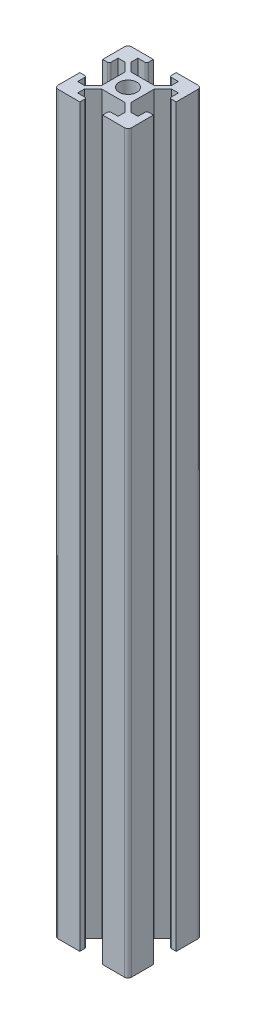
from build123d import *

# Parameters (mm, degrees)
SKETCH1_R           = 2.4
BOSS_EXTRUDE1_DEPTH = 200


with BuildPart() as part:
    # Sketch1 → Boss-Extrude1 (new body)
    with BuildSketch(Plane(origin=(0, 0, 0), x_dir=(1, 0, 0), z_dir=(0, 1, 0))):
        with BuildLine():
            ThreePointArc((-10, -9), (-9.707106781, -9.707106781), (-9, -10))
            Line((-9, -10), (-3.1, -10))
            Line((-3.1, -10), (-3.1, -8.7))
            ThreePointArc((-3.1, -8.7), (-3.246446609, -8.346446609), (-3.6, -8.2))
            Line((-3.6, -8.2), (-5.5, -8.2))
            Line((-5.5, -8.2), (-5.5, -6.376528763))
            Line((-5.5, -6.376528763), (-3.123471237, -4))
            Line((-3.123471237, -4), (0, -4))
            Line((0, -4), (3.123471237, -4))
            Line((3.123471237, -4), (5.5, -6.376528763))
            Line((5.5, -6.376528763), (5.5, -8.2))
            Line((5.5, -8.2), (3.6, -8.2))
            ThreePointArc((3.6, -8.2), (3.246446609, -8.346446609), (3.1, -8.7))
            Line((3.1, -8.7), (3.1, -10))
            Line((3.1, -10), (9, -10))
            ThreePointArc((9, -10), (9.707106781, -9.707106781), (10, -9))
            Line((10, -9), (10, -3.1))
            Line((10, -3.1), (8.7, -3.1))
            ThreePointArc((8.7, -3.1), (8.346446609, -3.246446609), (8.2, -3.6))
            Line((8.2, -3.6), (8.2, -5.5))
            Line((8.2, -5.5), (6.376528763, -5.5))
            Line((6.376528763, -5.5), (4, -3.123471237))
            Line((4, -3.123471237), (4, 0))
            Line((4, 0), (4, 3.123471237))
            Line((4, 3.123471237), (6.376528763, 5.5))
            Line((6.376528763, 5.5), (8.2, 5.5))
            Line((8.2, 5.5), (8.2, 3.6))
            ThreePointArc((8.2, 3.6), (8.346446609, 3.246446609), (8.7, 3.1))
            Line((8.7, 3.1), (10, 3.1))
            Line((10, 3.1), (10, 9))
            ThreePointArc((10, 9), (9.707106781, 9.707106781), (9, 10))
            Line((9, 10), (3.1, 10))
            Line((3.1, 10), (3.1, 8.7))
            ThreePointArc((3.1, 8.7), (3.246446609, 8.346446609), (3.6, 8.2))
            Line((3.6, 8.2), (5.5, 8.2))
            Line((5.5, 8.2), (5.5, 6.376528763))
            Line((5.5, 6.376528763), (3.123471237, 4))
            Line((3.123471237, 4), (0, 4))
            Line((0, 4), (-3.123471237, 4))
            Line((-3.123471237, 4), (-5.5, 6.376528763))
            Line((-5.5, 6.376528763), (-5.5, 8.2))
            Line((-5.5, 8.2), (-3.6, 8.2))
            ThreePointArc((-3.6, 8.2), (-3.246446609, 8.346446609), (-3.1, 8.7))
            Line((-3.1, 8.7), (-3.1, 10))
            Line((-3.1, 10), (-9, 10))
            ThreePointArc((-9, 10), (-9.707106781, 9.707106781), (-10, 9))
            Line((-10, 9), (-10, 3.1))
            Line((-10, 3.1), (-8.7, 3.1))
            ThreePointArc((-8.7, 3.1), (-8.346446609, 3.246446609), (-8.2, 3.6))
            Line((-8.2, 3.6), (-8.2, 5.5))
            Line((-8.2, 5.5), (-6.376528763, 5.5))
            Line((-6.376528763, 5.5), (-4, 3.123471237))
            Line((-4, 3.123471237), (-4, 0))
            Line((-4, 0), (-4, -3.123471237))
            Line((-4, -3.123471237), (-6.376528763, -5.5))
            Line((-6.376528763, -5.5), (-8.2, -5.5))
            Line((-8.2, -5.5), (-8.2, -3.6))
            ThreePointArc((-8.2, -3.6), (-8.346446609, -3.246446609), (-8.7, -3.1))
            Line((-8.7, -3.1), (-10, -3.1))
            Line((-10, -3.1), (-10, -9))
        make_face()
        Circle(SKETCH1_R, mode=Mode.SUBTRACT)
    extrude(amount=BOSS_EXTRUDE1_DEPTH)


solid = part.part
